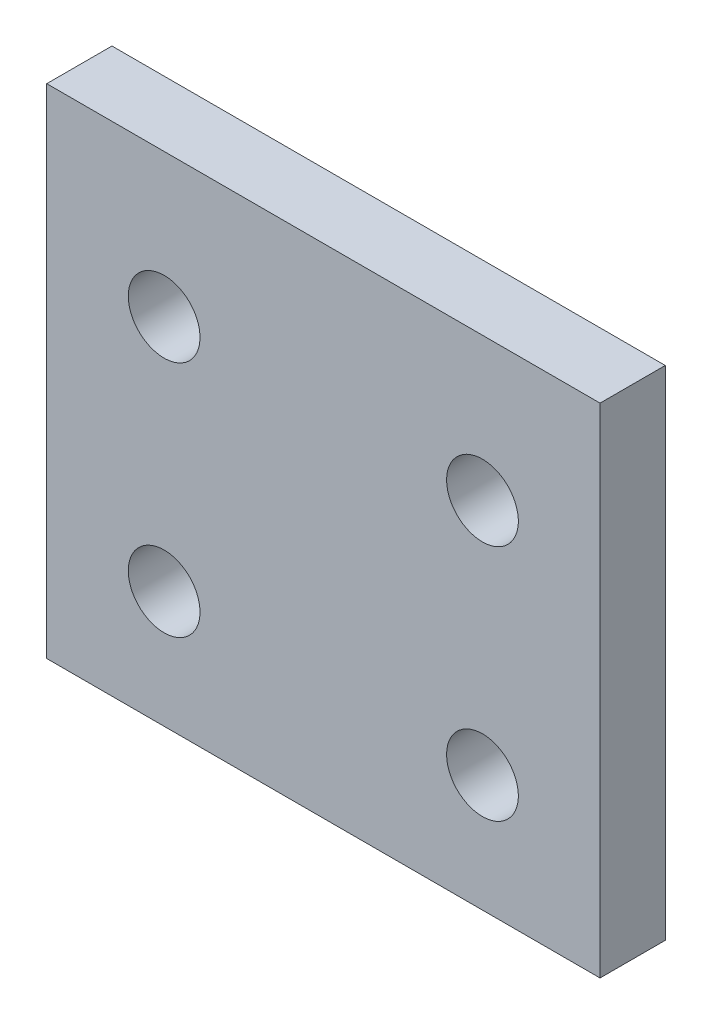
from build123d import *

# Parameters (mm, degrees)
SKETCH1_W           = 21.21128765
SKETCH1_H           = 19.08604853
BOSS_EXTRUDE1_DEPTH = 2.5
SKETCH2_R           = 1.375
CUT_EXTRUDE1_DEPTH  = 3.5


with BuildPart() as part:
    # Sketch1 → Boss-Extrude1 (new body)
    with BuildSketch(Plane.XY):
        with Locations((10.605643825, 9.543024265)):
            Rectangle(SKETCH1_W, SKETCH1_H)
    extrude(amount=BOSS_EXTRUDE1_DEPTH)

    # Sketch2 → Cut-Extrude1 (cut, through all)
    with BuildSketch(Plane(origin=(0, 0, 0), x_dir=(-1, 0, 0), z_dir=(0, 0, -1))):
        with Locations((-16.70317329, 13.5977062)):
            Circle(SKETCH2_R)
        with Locations((-4.50061561, 13.5977062)):
            Circle(SKETCH2_R)
        with Locations((-16.70317329, 4.48009656)):
            Circle(SKETCH2_R)
        with Locations((-4.50061561, 4.48009656)):
            Circle(SKETCH2_R)
    extrude(amount=-CUT_EXTRUDE1_DEPTH, mode=Mode.SUBTRACT)


solid = part.part
